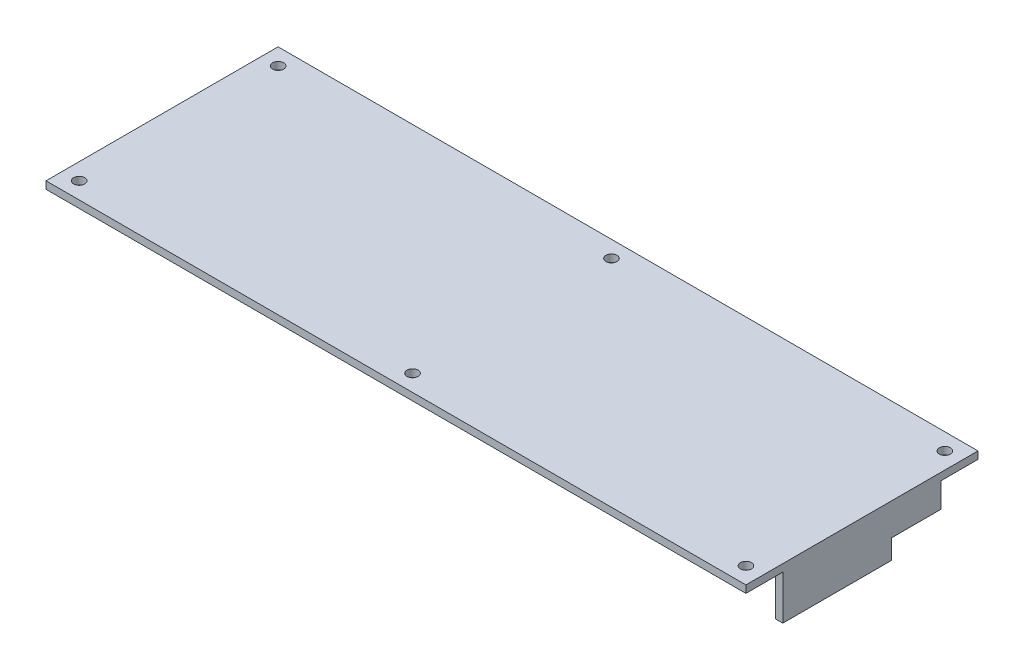
from build123d import *

# Parameters (mm, degrees)
BOSS_EXTRUDE1_DEPTH   = 2
SKETCH1_4_R           = 1.5
BOSS_EXTRUDE2_DEPTH   = 19
BOSS_EXTRUDE2_2_DEPTH = 19
BOSS_EXTRUDE2_3_DEPTH = 19
BOSS_EXTRUDE2_4_DEPTH = 19
BOSS_EXTRUDE2_5_DEPTH = 19
BOSS_EXTRUDE2_6_DEPTH = 19
SKETCH1_5_R           = 1.5
BOSS_EXTRUDE3_DEPTH   = 20
BOSS_EXTRUDE4_DEPTH   = 22
SKETCH2_W             = 23
SKETCH2_H             = 8
SKETCH2_W_2           = 13.5
SKETCH2_H_2           = 13.3
CUT_EXTRUDE1_DEPTH    = 3
SKETCH3_W             = 20
SKETCH3_H             = 12
SKETCH3_W_2           = 33
CUT_EXTRUDE2_DEPTH    = 3
SKETCH4_W             = 12
SKETCH4_H             = 7.5
CUT_EXTRUDE3_DEPTH    = 3
SKETCH10_W            = 190
SKETCH10_H            = 63
BOSS_EXTRUDE5_DEPTH   = 2
SKETCH10_3_W          = 186
SKETCH10_3_H          = 59
CUT_EXTRUDE7_DEPTH    = 22
CUT_EXTRUDE8_DEPTH    = 2
CUT_EXTRUDE9_DEPTH    = 2
CUT_EXTRUDE10_DEPTH   = 2
SKETCH9_W             = 190
SKETCH9_H             = 22
CUT_EXTRUDE11_DEPTH   = 2
SKETCH1_7_R           = 1.5
CUT_EXTRUDE12_DEPTH   = 24


with BuildPart() as part:
    # Sketch1 → Boss-Extrude1 (new body)
    with BuildSketch(Plane(origin=(0, 0, 0), x_dir=(1, 0, 0), z_dir=(0, 1, 0))):
        with BuildLine():
            Line((-90.5, 22.5), (-93, 22.5))
            Line((-93, 22.5), (-93, -22.5))
            Line((-93, -22.5), (-90.5, -22.5))
            ThreePointArc((-90.5, -22.5), (-87.318019485, -23.818019485), (-86, -27))
            Line((-86, -27), (-86, -29.5))
            Line((-86, -29.5), (-4.5, -29.5))
            Line((-4.5, -29.5), (-4.5, -27))
            ThreePointArc((-4.5, -27), (0, -22.5), (4.5, -27))
            Line((4.5, -27), (4.5, -29.5))
            Line((4.5, -29.5), (86, -29.5))
            Line((86, -29.5), (86, -27))
            ThreePointArc((86, -27), (87.318019485, -23.818019485), (90.5, -22.5))
            Line((90.5, -22.5), (93, -22.5))
            Line((93, -22.5), (93, 22.5))
            Line((93, 22.5), (90.5, 22.5))
            ThreePointArc((90.5, 22.5), (87.318019485, 23.818019485), (86, 27))
            Line((86, 27), (86, 29.5))
            Line((86, 29.5), (4.5, 29.5))
            Line((4.5, 29.5), (4.5, 27))
            ThreePointArc((4.5, 27), (0, 22.5), (-4.5, 27))
            Line((-4.5, 27), (-4.5, 29.5))
            Line((-4.5, 29.5), (-86, 29.5))
            Line((-86, 29.5), (-86, 27))
            ThreePointArc((-86, 27), (-87.318019485, 23.818019485), (-90.5, 22.5))
        make_face()
    extrude(amount=BOSS_EXTRUDE1_DEPTH)



with BuildPart() as body_2:
    # Sketch1_4 → Boss-Extrude2 (new body)
    with BuildSketch(Plane(origin=(0, 0, 0), x_dir=(1, 0, 0), z_dir=(0, 1, 0))):
        with Locations((-90.5, 27)):
            Circle(SKETCH1_4_R)
    extrude(amount=BOSS_EXTRUDE2_DEPTH)



with BuildPart() as body_3:
    # Sketch1_4 → Boss-Extrude2 2 (new body)
    with BuildSketch(Plane(origin=(0, 0, 0), x_dir=(1, 0, 0), z_dir=(0, 1, 0))):
        with Locations((90.5, 27)):
            Circle(SKETCH1_4_R)
    extrude(amount=BOSS_EXTRUDE2_2_DEPTH)


with BuildPart() as body_4:
    # Sketch1_4 → Boss-Extrude2 3 (new body)
    with BuildSketch(Plane(origin=(0, 0, 0), x_dir=(1, 0, 0), z_dir=(0, 1, 0))):
        with Locations((90.5, -27)):
            Circle(SKETCH1_4_R)
    extrude(amount=BOSS_EXTRUDE2_3_DEPTH)


with BuildPart() as body_5:
    # Sketch1_4 → Boss-Extrude2 4 (new body)
    with BuildSketch(Plane(origin=(0, 0, 0), x_dir=(1, 0, 0), z_dir=(0, 1, 0))):
        with Locations((-90.5, -27)):
            Circle(SKETCH1_4_R)
    extrude(amount=BOSS_EXTRUDE2_4_DEPTH)


with BuildPart() as body_6:
    # Sketch1_4 → Boss-Extrude2 5 (new body)
    with BuildSketch(Plane(origin=(0, 0, 0), x_dir=(1, 0, 0), z_dir=(0, 1, 0))):
        with Locations((0, 27)):
            Circle(SKETCH1_4_R)
    extrude(amount=BOSS_EXTRUDE2_5_DEPTH)


with BuildPart() as body_7:
    # Sketch1_4 → Boss-Extrude2 6 (new body)
    with BuildSketch(Plane(origin=(0, 0, 0), x_dir=(1, 0, 0), z_dir=(0, 1, 0))):
        with Locations((0, -27)):
            Circle(SKETCH1_4_R)
    extrude(amount=BOSS_EXTRUDE2_6_DEPTH)


with BuildPart() as body_2_1:
    add(body_2.part)

    add(body_3.part)  # Boss-Extrude3 merges body 3

    add(body_4.part)  # Boss-Extrude3 merges body 4

    add(body_5.part)  # Boss-Extrude3 merges body 5

    add(body_6.part)  # Boss-Extrude3 merges body 6

    add(body_7.part)  # Boss-Extrude3 merges body 7
    # Sketch1_5 → Boss-Extrude3 (add)
    # profile 1 of 6: a face of its own
    with BuildSketch(Plane(origin=(0, 0, 0), x_dir=(1, 0, 0), z_dir=(0, 1, 0))):
        Polygon((93.5, 27), (92, 29.598076211), (89, 29.598076211), (87.5, 27), (89, 24.401923789), (92, 24.401923789), align=None)
        with Locations((90.5, 27)):
            Circle(SKETCH1_5_R, mode=Mode.SUBTRACT)
    # profile 2 of 6: a face of its own
    with BuildSketch(Plane(origin=(0, 0, 0), x_dir=(1, 0, 0), z_dir=(0, 1, 0))):
        Polygon((-92, 29.598076211), (-93.5, 27), (-92, 24.401923789), (-89, 24.401923789), (-87.5, 27), (-89, 29.598076211), align=None)
        with Locations((-90.5, 27)):
            Circle(SKETCH1_5_R, mode=Mode.SUBTRACT)
    # profile 3 of 6: a face of its own
    with BuildSketch(Plane(origin=(0, 0, 0), x_dir=(1, 0, 0), z_dir=(0, 1, 0))):
        Polygon((87.5, -27), (89, -29.598076211), (92, -29.598076211), (93.5, -27), (92, -24.401923789), (89, -24.401923789), align=None)
        with Locations((90.5, -27)):
            Circle(SKETCH1_5_R, mode=Mode.SUBTRACT)
    # profile 4 of 6: a face of its own
    with BuildSketch(Plane(origin=(0, 0, 0), x_dir=(1, 0, 0), z_dir=(0, 1, 0))):
        Polygon((-93.5, -27), (-92, -29.598076211), (-89, -29.598076211), (-87.5, -27), (-89, -24.401923789), (-92, -24.401923789), align=None)
        with Locations((-90.5, -27)):
            Circle(SKETCH1_5_R, mode=Mode.SUBTRACT)
    # profile 5 of 6: a face of its own
    with BuildSketch(Plane(origin=(0, 0, 0), x_dir=(1, 0, 0), z_dir=(0, 1, 0))):
        Polygon((3, -27), (1.5, -24.401923789), (-1.5, -24.401923789), (-3, -27), (-1.5, -29.598076211), (1.5, -29.598076211), align=None)
        with Locations((0, -27)):
            Circle(SKETCH1_5_R, mode=Mode.SUBTRACT)
    # profile 6 of 6: a face of its own
    with BuildSketch(Plane(origin=(0, 0, 0), x_dir=(1, 0, 0), z_dir=(0, 1, 0))):
        Polygon((1.5, 24.401923789), (3, 27), (1.5, 29.598076211), (-1.5, 29.598076211), (-3, 27), (-1.5, 24.401923789), align=None)
        with Locations((0, 27)):
            Circle(SKETCH1_5_R, mode=Mode.SUBTRACT)
    extrude(amount=BOSS_EXTRUDE3_DEPTH)


with BuildPart() as part_1:
    add(part.part)

    add(body_2_1.part)  # Boss-Extrude4 merges body 2
    # Sketch1_6 → Boss-Extrude4 (add)
    with BuildSketch(Plane(origin=(0, 0, 0), x_dir=(1, 0, 0), z_dir=(0, 1, 0))):
        Polygon((-95, -22.5), (-95, -31.5), (-86, -31.5), (86, -31.5), (95, -31.5), (95, -22.5), (95, 22.5), (95, 31.5), (86, 31.5), (4.5, 31.5), (-4.5, 31.5), (-86, 31.5), (-95, 31.5), (-95, 22.5), align=None)
        Polygon((-89, -29.598076211), (-92, -29.598076211), (-93.5, -27), (-92, -24.401923789), (-89, -24.401923789), (-87.5, -27), align=None, mode=Mode.SUBTRACT)
        Polygon((-1.5, -24.401923789), (1.5, -24.401923789), (3, -27), (1.5, -29.598076211), (-1.5, -29.598076211), (-3, -27), align=None, mode=Mode.SUBTRACT)
        Polygon((92, -29.598076211), (89, -29.598076211), (87.5, -27), (89, -24.401923789), (92, -24.401923789), (93.5, -27), align=None, mode=Mode.SUBTRACT)
        Polygon((-92, 24.401923789), (-93.5, 27), (-92, 29.598076211), (-89, 29.598076211), (-87.5, 27), (-89, 24.401923789), align=None, mode=Mode.SUBTRACT)
        Polygon((1.5, 29.598076211), (3, 27), (1.5, 24.401923789), (-1.5, 24.401923789), (-3, 27), (-1.5, 29.598076211), align=None, mode=Mode.SUBTRACT)
        with BuildLine():
            Line((-93, -22.5), (-93, 22.5))
            Line((-93, 22.5), (-90.5, 22.5))
            ThreePointArc((-90.5, 22.5), (-87.318019485, 23.818019485), (-86, 27))
            Line((-86, 27), (-86, 29.5))
            Line((-86, 29.5), (-4.5, 29.5))
            Line((-4.5, 29.5), (-4.5, 27))
            ThreePointArc((-4.5, 27), (0, 22.5), (4.5, 27))
            Line((4.5, 27), (4.5, 29.5))
            Line((4.5, 29.5), (86, 29.5))
            Line((86, 29.5), (86, 27))
            ThreePointArc((86, 27), (87.318019485, 23.818019485), (90.5, 22.5))
            Line((90.5, 22.5), (93, 22.5))
            Line((93, 22.5), (93, -22.5))
            Line((93, -22.5), (90.5, -22.5))
            ThreePointArc((90.5, -22.5), (87.318019485, -23.818019485), (86, -27))
            Line((86, -27), (86, -29.5))
            Line((86, -29.5), (4.5, -29.5))
            Line((4.5, -29.5), (4.5, -27))
            ThreePointArc((4.5, -27), (0, -22.5), (-4.5, -27))
            Line((-4.5, -27), (-4.5, -29.5))
            Line((-4.5, -29.5), (-86, -29.5))
            Line((-86, -29.5), (-86, -27))
            ThreePointArc((-86, -27), (-87.318019485, -23.818019485), (-90.5, -22.5))
            Line((-90.5, -22.5), (-93, -22.5))
        make_face(mode=Mode.SUBTRACT)
        Polygon((89, 29.598076211), (92, 29.598076211), (93.5, 27), (92, 24.401923789), (89, 24.401923789), (87.5, 27), align=None, mode=Mode.SUBTRACT)
    extrude(amount=BOSS_EXTRUDE4_DEPTH)

    # Sketch2 → Cut-Extrude1 (cut)
    with BuildSketch(Plane(origin=(95, 0, 0), x_dir=(0, 0, -1), z_dir=(1, 0, 0))):
        with Locations((-10, 6)):
            Rectangle(SKETCH2_W, SKETCH2_H)
        with Locations((14.75, 8.65)):
            Rectangle(SKETCH2_W_2, SKETCH2_H_2)
    extrude(amount=-CUT_EXTRUDE1_DEPTH, mode=Mode.SUBTRACT)

    # Sketch3 → Cut-Extrude2 (cut)
    with BuildSketch(Plane(origin=(0, 0, -31.5), x_dir=(-1, 0, 0), z_dir=(0, 0, -1))):
        with Locations((-65, 8)):
            Rectangle(SKETCH3_W, SKETCH3_H)
        with Locations((51.5, 8)):
            Rectangle(SKETCH3_W_2, SKETCH3_H)
    extrude(amount=-CUT_EXTRUDE2_DEPTH, mode=Mode.SUBTRACT)

    # Sketch4 → Cut-Extrude3 (cut)
    with BuildSketch(Plane.ZY.offset(95)):
        with Locations((-9.5, 5.75)):
            Rectangle(SKETCH4_W, SKETCH4_H)
        with Locations((9.5, 5.75)):
            Rectangle(SKETCH4_W, SKETCH4_H)
    extrude(amount=-CUT_EXTRUDE3_DEPTH, mode=Mode.SUBTRACT)

    # Sketch10 → Boss-Extrude5 (add)
    with BuildSketch(Plane(origin=(0, 22, 0), x_dir=(1, 0, 0), z_dir=(0, 1, 0))):
        Rectangle(SKETCH10_W, SKETCH10_H)
    extrude(amount=BOSS_EXTRUDE5_DEPTH)

    # Sketch10_3 → Cut-Extrude7 (cut)
    with BuildSketch(Plane(origin=(0, 22, 0), x_dir=(1, 0, 0), z_dir=(0, 1, 0))):
        Rectangle(SKETCH10_3_W, SKETCH10_3_H)
    extrude(amount=-CUT_EXTRUDE7_DEPTH, mode=Mode.SUBTRACT)

    # Sketch5 → Cut-Extrude8 (cut)
    with BuildSketch(Plane(origin=(95, 0, 0), x_dir=(0, 0, -1), z_dir=(1, 0, 0))):
        Polygon((-21.5, 10), (-21.5, 22), (-31.5, 22), (-31.5, 0), (31.5, 0), (31.5, 22), (21.5, 22), (21.5, 15.3), (8, 15.3), (8, 10), align=None)
    extrude(amount=-CUT_EXTRUDE8_DEPTH, mode=Mode.SUBTRACT)

    # Sketch6 → Cut-Extrude9 (cut)
    with BuildSketch(Plane(origin=(0, 0, -31.5), x_dir=(-1, 0, 0), z_dir=(0, 0, -1))):
        Polygon((-75, 22), (-75, 14), (-55, 14), (-55, 22), (35, 22), (35, 14), (68, 14), (68, 22), (95, 22), (95, 0), (-95, 0), (-95, 22), align=None)
    extrude(amount=-CUT_EXTRUDE9_DEPTH, mode=Mode.SUBTRACT)

    # Sketch7 → Cut-Extrude10 (cut)
    with BuildSketch(Plane.ZY.offset(95)):
        Polygon((-15.5, 9.5), (-15.5, 22), (-31.5, 22), (-31.5, 0), (31.5, 0), (31.5, 22), (15.5, 22), (15.5, 9.5), align=None)
    extrude(amount=-CUT_EXTRUDE10_DEPTH, mode=Mode.SUBTRACT)

    # Sketch9 → Cut-Extrude11 (cut)
    with BuildSketch(Plane.XY.offset(31.5)):
        with Locations((0, 11)):
            Rectangle(SKETCH9_W, SKETCH9_H)
    extrude(amount=-CUT_EXTRUDE11_DEPTH, mode=Mode.SUBTRACT)

    # Sketch1_7 → Cut-Extrude12 (cut)
    with BuildSketch(Plane(origin=(0, 0, 0), x_dir=(1, 0, 0), z_dir=(0, 1, 0))):
        with Locations((-90.5, 27)):
            Circle(SKETCH1_7_R)
        with Locations((90.5, 27)):
            Circle(SKETCH1_7_R)
        with Locations((90.5, -27)):
            Circle(SKETCH1_7_R)
        with Locations((-90.5, -27)):
            Circle(SKETCH1_7_R)
        with Locations((0, 27)):
            Circle(SKETCH1_7_R)
        with Locations((0, -27)):
            Circle(SKETCH1_7_R)
    extrude(amount=CUT_EXTRUDE12_DEPTH, mode=Mode.SUBTRACT)


solid = part_1.part
